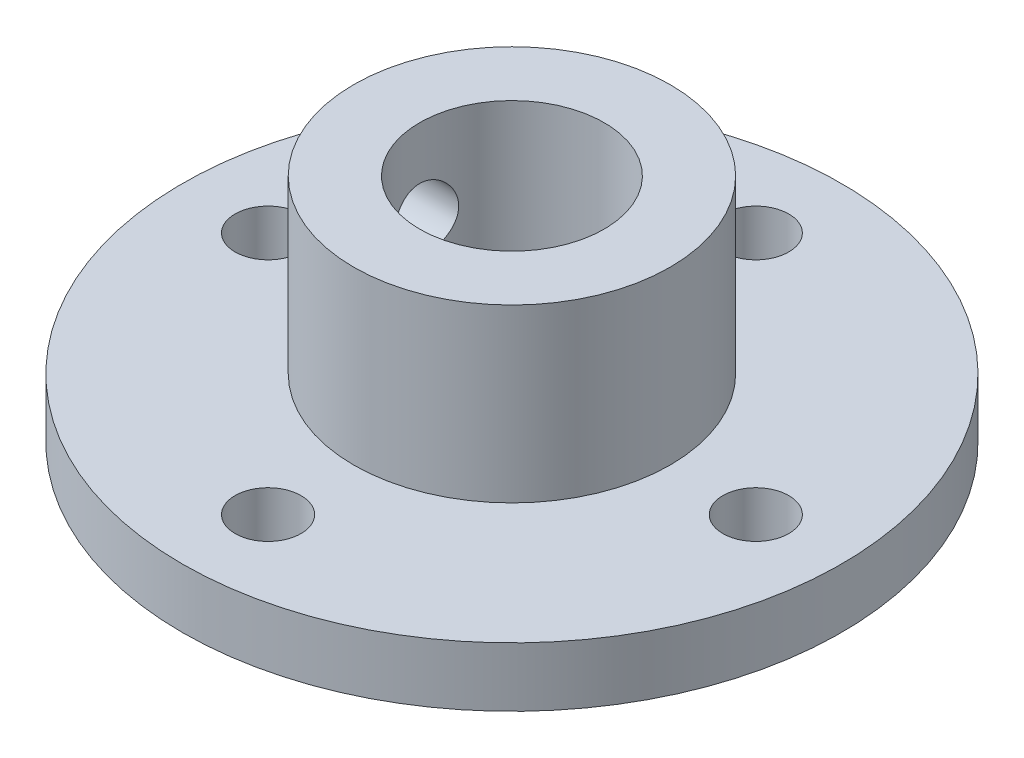
from build123d import *

# Parameters (mm, degrees)
SKETCH1_R           = 25
BOSS_EXTRUDE1_DEPTH = 4.5
SKETCH2_R           = 12
BOSS_EXTRUDE2_DEPTH = 13
SKETCH3_R           = 7
CUT_EXTRUDE1_DEPTH  = 17.5
SKETCH4_R           = 2.5
CUT_EXTRUDE2_DEPTH  = 4.5
SKETCH5_R           = 2.5
CUT_EXTRUDE3_DEPTH  = 25


with BuildPart() as part:
    # Sketch1 → Boss-Extrude1 (new body)
    with BuildSketch(Plane(origin=(0, 0, 0), x_dir=(1, 0, 0), z_dir=(0, 1, 0))):
        Circle(SKETCH1_R)
    extrude(amount=BOSS_EXTRUDE1_DEPTH)

    # Sketch2 → Boss-Extrude2 (add)
    with BuildSketch(Plane(origin=(0, 4.5, 0), x_dir=(1, 0, 0), z_dir=(0, 1, 0))):
        Circle(SKETCH2_R)
    extrude(amount=BOSS_EXTRUDE2_DEPTH)

    # Sketch3 → Cut-Extrude1 (cut)
    with BuildSketch(Plane(origin=(0, 17.5, 0), x_dir=(1, 0, 0), z_dir=(0, 1, 0))):
        Circle(SKETCH3_R)
    extrude(amount=-CUT_EXTRUDE1_DEPTH, mode=Mode.SUBTRACT)

    # Sketch4 → Cut-Extrude2 (cut)
    with BuildSketch(Plane(origin=(0, 4.5, 0), x_dir=(1, 0, 0), z_dir=(0, 1, 0))):
        with Locations((-18.5, 0)):
            Circle(SKETCH4_R)
        with Locations((0, 18.5)):
            Circle(SKETCH4_R)
        with Locations((18.5, 0)):
            Circle(SKETCH4_R)
        with Locations((0, -18.5)):
            Circle(SKETCH4_R)
    extrude(amount=-CUT_EXTRUDE2_DEPTH, mode=Mode.SUBTRACT)

    # Sketch5 → Cut-Extrude3 (cut)
    with BuildSketch(Plane(origin=(0, 0, 0), x_dir=(0, 0, -1), z_dir=(1, 0, 0))):
        with Locations((0, 11)):
            Circle(SKETCH5_R)
    extrude(amount=-CUT_EXTRUDE3_DEPTH, mode=Mode.SUBTRACT)


solid = part.part
